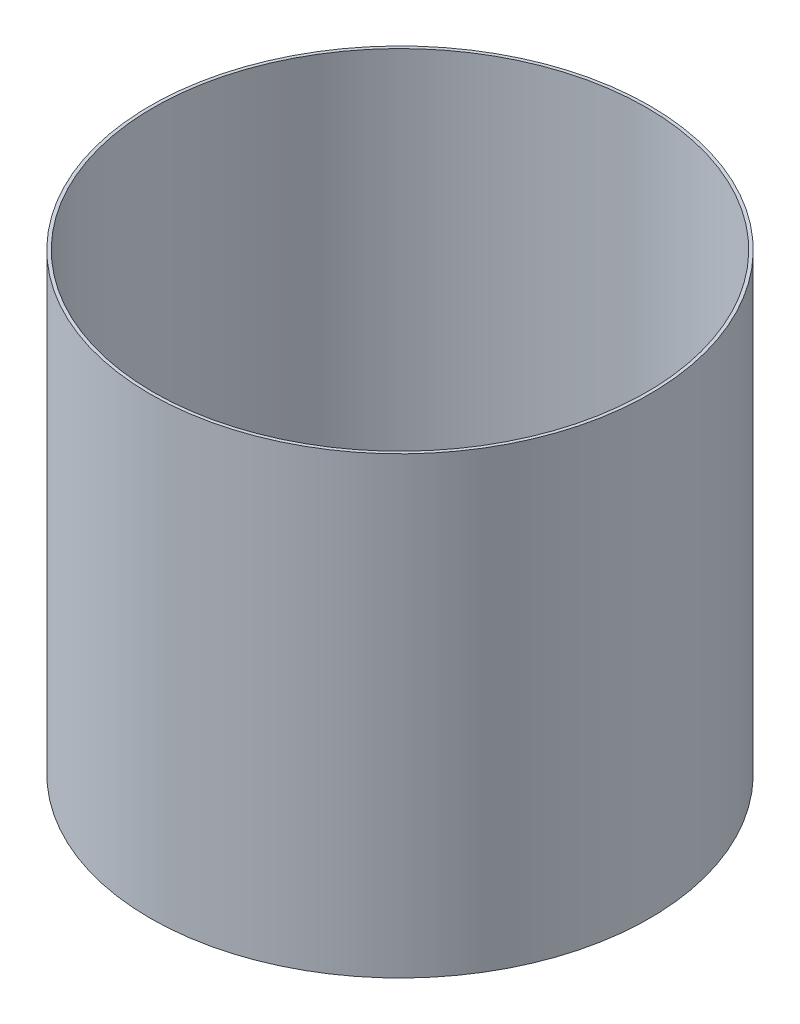
from build123d import *

# Parameters (mm, degrees)
SKETCH1_R           = 130.175
SKETCH1_R_2         = 128.525
BOSS_EXTRUDE1_DEPTH = 234.95
SKETCH2_R           = 130.175
BOSS_EXTRUDE2_DEPTH = 1.65
SKETCH3_R           = 3.96875
CUT_EXTRUDE1_DEPTH  = 237.6


with BuildPart() as part:
    # Sketch1 → Boss-Extrude1 (new body)
    with BuildSketch(Plane(origin=(0, 0, 0), x_dir=(1, 0, 0), z_dir=(0, 1, 0))):
        Circle(SKETCH1_R)
        Circle(SKETCH1_R_2, mode=Mode.SUBTRACT)
    extrude(amount=BOSS_EXTRUDE1_DEPTH)

    # Sketch2 → Boss-Extrude2 (add)
    with BuildSketch(Plane.XZ):
        Circle(SKETCH2_R)
    extrude(amount=BOSS_EXTRUDE2_DEPTH)

    # Sketch3 → Cut-Extrude1 (cut, through all)
    with BuildSketch(Plane.XZ.offset(1.65)):
        Circle(SKETCH3_R)
    extrude(amount=-CUT_EXTRUDE1_DEPTH, mode=Mode.SUBTRACT)


solid = part.part
